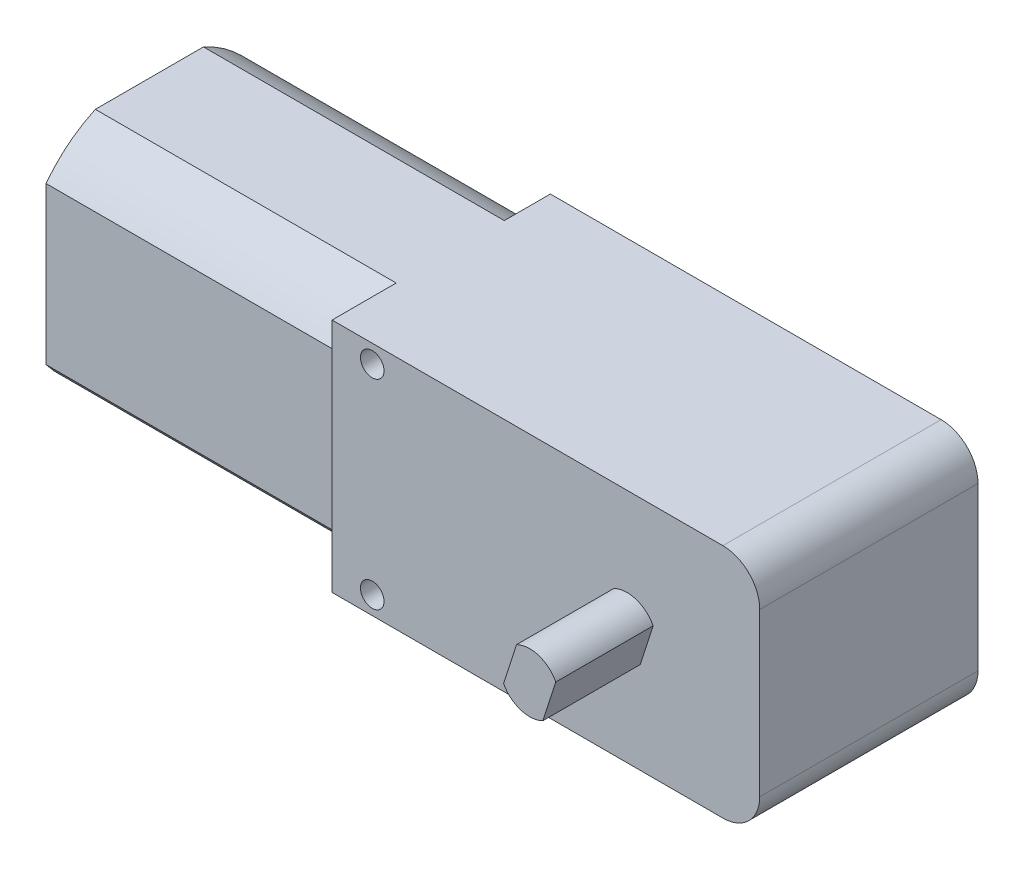
from build123d import *

# Parameters (mm, degrees)
SKETCH1_W           = 36.83
SKETCH1_H           = 20.32
BOSS_EXTRUDE1_DEPTH = 18.796
FILLET1_R           = 3.175
BOSS_EXTRUDE2_DEPTH = 25.908
BOSS_EXTRUDE3_DEPTH = 8.382
SKETCH4_R           = 1.016
CUT_EXTRUDE1_DEPTH  = 19.796


with BuildPart() as part:
    # Sketch1 → Boss-Extrude1 (new body)
    with BuildSketch(Plane.XY):
        with Locations((18.415, 0)):
            Rectangle(SKETCH1_W, SKETCH1_H)
    extrude(amount=BOSS_EXTRUDE1_DEPTH)

    # Fillet1
    fillet1_edges = [part.edges().sort_by_distance(p)[0] for p in [
        (36.83, 10.16, 9.398),
        (36.83, -10.16, 9.398),
    ]]
    fillet(fillet1_edges, radius=FILLET1_R)

    # Sketch2 → Boss-Extrude2 (add)
    with BuildSketch(Plane.ZY):
        with BuildLine():
            ThreePointArc((3.96514897, 10.16), (1.809887501, 8.860648824), (0, 7.112))
            Line((0, 7.112), (0, -7.112))
            ThreePointArc((0, -7.112), (1.809887501, -8.860648824), (3.96514897, -10.16))
            Line((3.96514897, -10.16), (13.276942782, -10.16))
            ThreePointArc((13.276942782, -10.16), (15.61217315, -8.719352926), (17.526, -6.753130241))
            Line((17.526, -6.753130241), (17.526, 6.753130241))
            ThreePointArc((17.526, 6.753130241), (15.61217315, 8.719352926), (13.276942782, 10.16))
            Line((13.276942782, 10.16), (3.96514897, 10.16))
        make_face()
    extrude(amount=BOSS_EXTRUDE2_DEPTH)

    # Sketch3 → Boss-Extrude3 (add)
    with BuildSketch(Plane.XY.offset(18.796)):
        with BuildLine():
            Line((24.267261803, 2.273434446), (23.149675051, -1.177980315))
            ThreePointArc((23.149675051, -1.177980315), (24.617532764, -2.416473676), (26.532738197, -2.273434446))
            Line((26.532738197, -2.273434446), (27.650324949, 1.177980315))
            ThreePointArc((27.650324949, 1.177980315), (26.182467236, 2.416473676), (24.267261803, 2.273434446))
        make_face()
    extrude(amount=BOSS_EXTRUDE3_DEPTH)

    # Sketch4 → Cut-Extrude1 (cut, through all)
    with BuildSketch(Plane.XY.offset(18.796)):
        with Locations((3.456249115, 8.597457961)):
            Circle(SKETCH4_R)
        with Locations((3.456249115, -8.597457961)):
            Circle(SKETCH4_R)
    extrude(amount=-CUT_EXTRUDE1_DEPTH, mode=Mode.SUBTRACT)


solid = part.part
